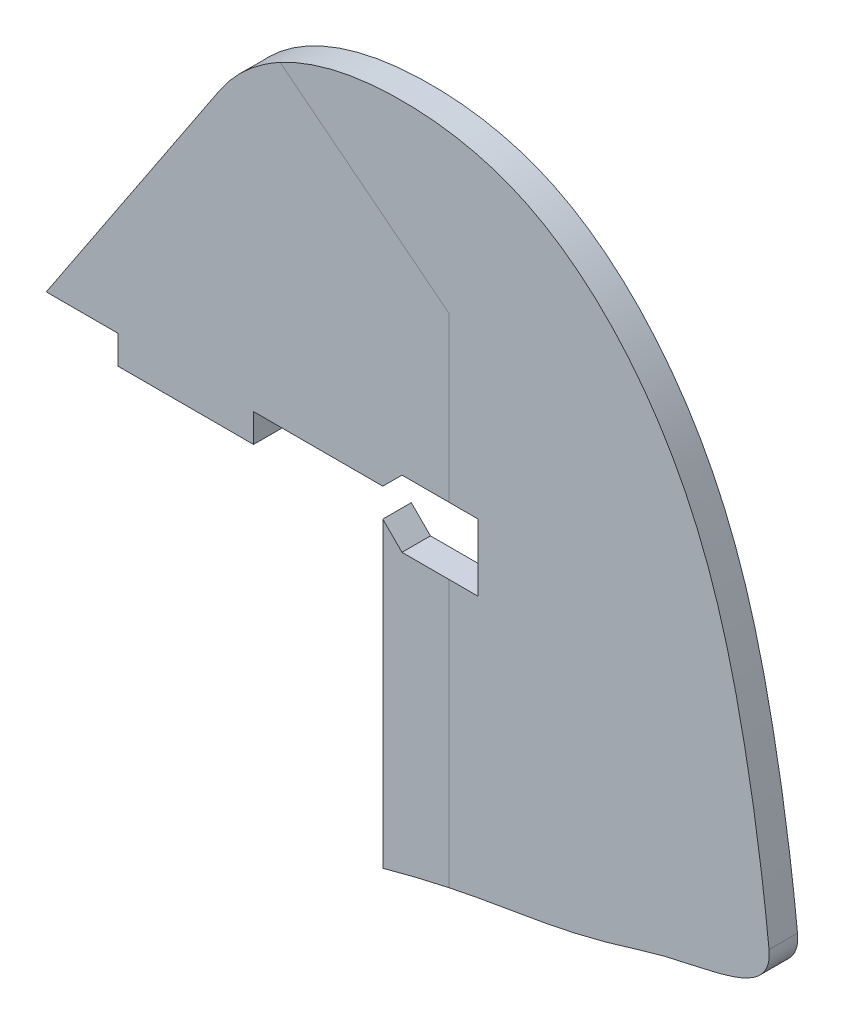
from build123d import *

# Parameters (mm, degrees)
BOSS_EXTRUDE1_DEPTH       = 2.667
SKETCH2_W                 = 25.4
SKETCH2_H                 = 5.334
ELEVATOR_TAB_DEPTH        = 5.334
ELEVATOR_THROW_SLOT_REACH = 7.334


with BuildPart() as part:
    # Sketch1 → Boss-Extrude1 (new body, symmetric)
    with BuildSketch(Plane.XY):
        with BuildLine():
            Line((2.660102258, 4.006979402), (35.125661289, 52.910673204))
            add(Edge.make_bspline(
                [(35.125661289, 52.910673204), (37.94742964, 57.161174336), (47.971102481, 65.942329117), (69.008437841, 69.751744098), (98.507626417, 64.241187451), (123.102162867, 36.688590277), (133.317484482, 0.065110923), (136.807881475, -23.842980811), (137.976029916, -34.973623487)],
                knots=[0, 0, 0, 0, 0.083245033, 0.226858925, 0.34728898, 0.588091299, 0.805835078, 1, 1, 1, 1], degree=3))
            add(Edge.make_bspline(
                [(137.976029916, -34.973623487), (138.815150475, -42.969140814), (124.639937031, -43.609481638), (103.232724243, -50.579998556), (88.627971228, -52.80632971), (74.994048295, -55.361665029), (65.666068366, -57.937752933)],
                knots=[0, 0, 0, 0, 0.302584462, 0.371889792, 0.693053295, 1, 1, 1, 1], degree=3))
            Line((65.666068366, -57.937752933), (65.666068366, 0))
            Line((65.666068366, 0), (65.666068366, 4.006979402))
            Line((65.666068366, 4.006979402), (2.660102258, 4.006979402))
        make_face()
    extrude(amount=BOSS_EXTRUDE1_DEPTH, both=True)

    # Sketch2 → Elevator Tab (add)
    with BuildSketch(Plane.XZ.offset(-4.006979402)):
        with Locations((28.775764126, 0)):
            Rectangle(SKETCH2_W, SKETCH2_H)
    extrude(amount=ELEVATOR_TAB_DEPTH)

    # Sketch3 → Elevator Throw Slot (cut, up to next)
    with BuildSketch(Plane.XY.offset(2.667), mode=Mode.PRIVATE) as elevator_throw_slot_sk1:
        Polygon((65.666068366, 4.006979402), (69.258170815, 7.599081851), (83.446068366, 7.599081851), (83.446068366, -4.919123046), (69.258170815, -4.919123046), (65.666068366, -1.327020598), align=None)
    elevator_throw_slot_tool1 = extrude(elevator_throw_slot_sk1.sketch, amount=-ELEVATOR_THROW_SLOT_REACH, mode=Mode.PRIVATE) & part.part
    add(elevator_throw_slot_tool1.solids().sort_by_distance((75.029476, 1.339979, 2.667))[0], mode=Mode.SUBTRACT)


solid = part.part
